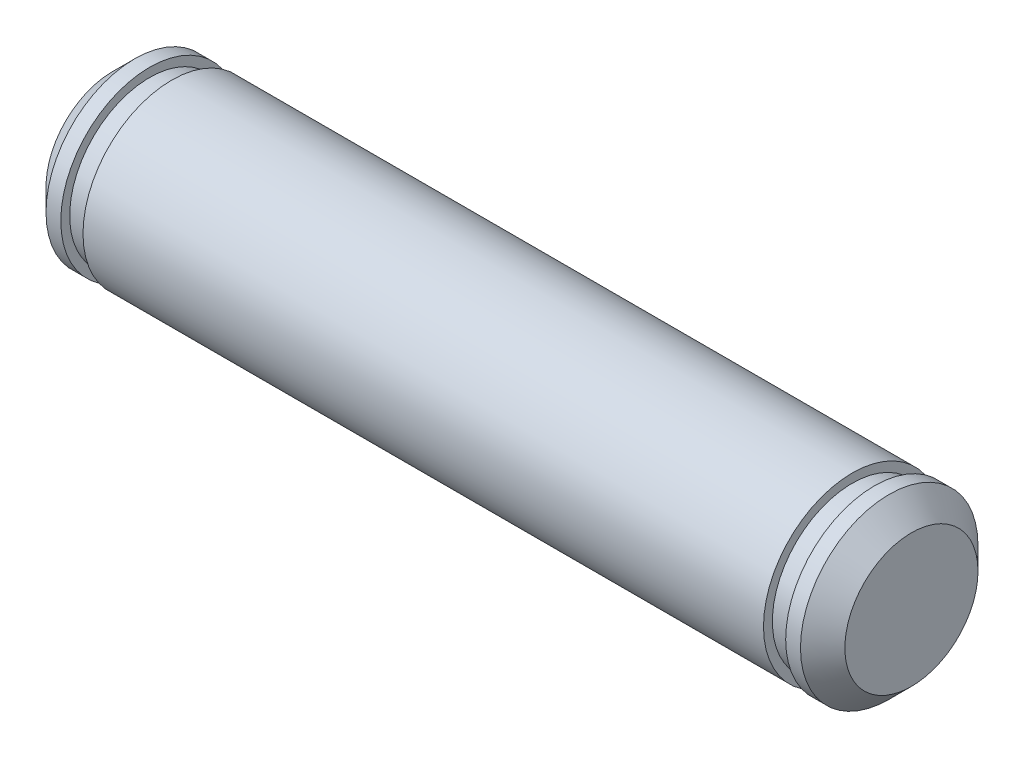
from build123d import *

# Parameters (mm, degrees)
ESQUISSE2_R             = 3
BASE_EXTRUSION_DEPTH    = 13.5
ESQUISSE3_OUTSIDE_W     = 13.66
ESQUISSE3_OUTSIDE_H     = 13.66
ESQUISSE3_OUTSIDE_R     = 2.7
ENL_V_MAT_EXTRU_1_DEPTH = 0.75
ESQUISSE4_OUTSIDE_W     = 13.66
ESQUISSE4_OUTSIDE_H     = 13.66
ESQUISSE4_OUTSIDE_R     = 2.7
ENL_V_MAT_EXTRU_2_DEPTH = 0.75
CHANFREIN3_SIZE         = 0.75


with BuildPart() as part:
    # Esquisse2 → Base-Extrusion (new body, symmetric)
    with BuildSketch(Plane(origin=(0, 0, 0), x_dir=(0, 0, -1), z_dir=(1, 0, 0))):
        Circle(ESQUISSE2_R)
    extrude(amount=BASE_EXTRUSION_DEPTH, both=True)

    # Esquisse3 outside → Enlèv. mat.-Extru.1 (cut)
    with BuildSketch(Plane(origin=(12.25, 0, 0), x_dir=(0, 0, -1), z_dir=(1, 0, 0))):
        Rectangle(ESQUISSE3_OUTSIDE_W, ESQUISSE3_OUTSIDE_H)
        Circle(ESQUISSE3_OUTSIDE_R, mode=Mode.SUBTRACT)
    extrude(amount=-ENL_V_MAT_EXTRU_1_DEPTH, mode=Mode.SUBTRACT)

    # Esquisse4 outside → Enlèv. mat.-Extru.2 (cut)
    with BuildSketch(Plane(origin=(-12.25, 0, 0), x_dir=(0, 0, -1), z_dir=(1, 0, 0))):
        Rectangle(ESQUISSE4_OUTSIDE_W, ESQUISSE4_OUTSIDE_H)
        Circle(ESQUISSE4_OUTSIDE_R, mode=Mode.SUBTRACT)
    extrude(amount=ENL_V_MAT_EXTRU_2_DEPTH, mode=Mode.SUBTRACT)

    # Chanfrein3
    chanfrein3_edges = [part.edges().sort_by_distance(p)[0] for p in [
        (-13.5, 0, 3),
        (13.5, 0, 3),
    ]]
    chamfer(chanfrein3_edges, length=CHANFREIN3_SIZE)


solid = part.part
